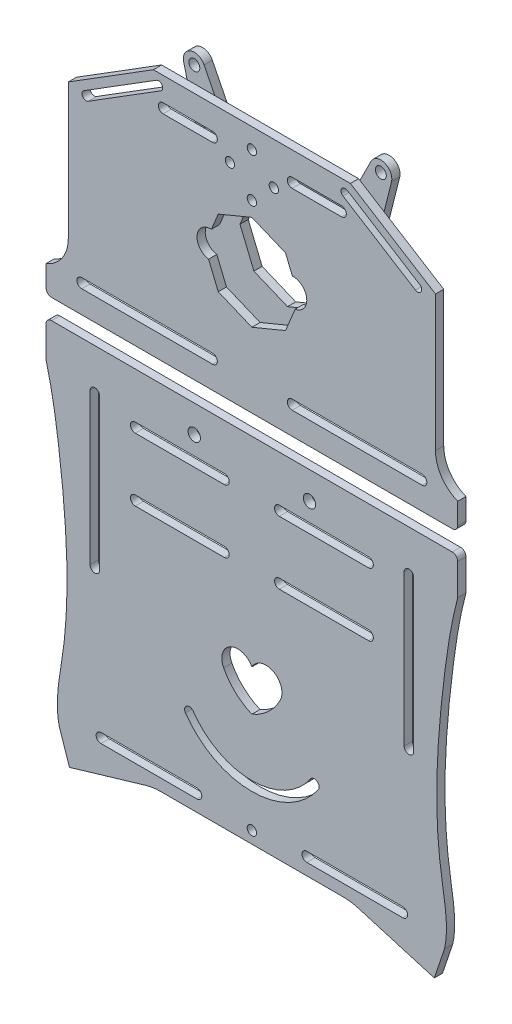
from build123d import *

# Parameters (mm, degrees)
EXTRUDE_1_DEPTH      = 3
SKETCH_7_R           = 1.75
SKETCH_7_R_2         = 2.25
CUT_EXTRUDE_2_DEPTH  = 143.955430949
CUT_EXTRUDE_4_DEPTH  = 3
CUT_EXTRUDE_5_DEPTH  = 3
CUT_EXTRUDE_8_DEPTH  = 3
SKETCH_12_R          = 1.7
CUT_EXTRUDE_9_DEPTH  = 3
SKETCH_13_R          = 1.7
CUT_EXTRUDE_11_DEPTH = 3
CUT_EXTRUDE_12_DEPTH = 143.955430949
FILLET_1_R           = 2
FILLET_2_R           = 2
CUT_EXTRUDE_13_DEPTH = 143.955430949
CUT_EXTRUDE_15_DEPTH = 143.955430949
CUT_EXTRUDE_16_DEPTH = 143.955430949
SKETCH_20_W          = 133.80338819
SKETCH_20_H          = 42.989432067
EXTRUDE_2_DEPTH      = 3
SKETCH_21_W          = 129.207272524
SKETCH_21_H          = 38.788932745
EXTRUDE_3_DEPTH      = 3
SKETCH_22_W          = 20.868569364
SKETCH_22_H          = 31.210515244
SKETCH_22_W_2        = 21.053246969
SKETCH_22_H_2        = 30.102449614
EXTRUDE_4_DEPTH      = 3
SKETCH_24_W          = 36.300662223
SKETCH_24_H          = 5.953308604
SKETCH_24_W_2        = 36.591067521
EXTRUDE_5_DEPTH      = 3
CUT_EXTRUDE_17_DEPTH = 143.955430949
CUT_EXTRUDE_19_DEPTH = 143.955430949
CUT_EXTRUDE_20_DEPTH = 143.955430949
CUT_EXTRUDE_21_DEPTH = 143.955430949
CUT_EXTRUDE_22_DEPTH = 143.955430949
CUT_EXTRUDE_23_DEPTH = 3
SKETCH_30_R          = 1.75
SKETCH_30_R_2        = 2
EXTRUDE_6_DEPTH      = 3
CUT_EXTRUDE_24_DEPTH = 144.816741864


with BuildPart() as part:
    # 草图1 → 凸台-拉伸1 (new body)
    with BuildSketch(Plane.XY):
        with BuildLine():
            Line((60, 106.603296002), (35.889163634, 121.664519159))
            Line((35.889163634, 121.664519159), (-35.889163634, 121.664519159))
            Line((-35.889163634, 121.664519159), (-60, 106.603296002))
            Line((-60, 106.603296002), (-60, 94.801892265))
            Line((-60, 94.801892265), (-45, 94.801892265))
            ThreePointArc((-45, 94.801892265), (-43.762563133, 94.289329132), (-43.25, 93.051892265))
            Line((-43.25, 93.051892265), (-37.75, 93.051892265))
            ThreePointArc((-37.75, 93.051892265), (-37.237436867, 94.289329132), (-36, 94.801892265))
            Line((-36, 94.801892265), (-21, 94.801892265))
            ThreePointArc((-21, 94.801892265), (-19.762563133, 94.289329132), (-19.25, 93.051892265))
            Line((-19.25, 93.051892265), (19.25, 93.051892265))
            ThreePointArc((19.25, 93.051892265), (19.762563133, 94.289329132), (21, 94.801892265))
            Line((21, 94.801892265), (36, 94.801892265))
            ThreePointArc((36, 94.801892265), (37.237436867, 94.289329132), (37.75, 93.051892265))
            Line((37.75, 93.051892265), (43.25, 93.051892265))
            ThreePointArc((43.25, 93.051892265), (43.762563133, 94.289329132), (45, 94.801892265))
            Line((45, 94.801892265), (60, 94.801892265))
            Line((60, 94.801892265), (60, 106.603296002))
        make_face()
        with BuildLine():
            Line((66.901694095, 102.292041372), (60, 106.603296002))
            Line((60, 106.603296002), (60, 94.801892265))
            ThreePointArc((60, 94.801892265), (61.237436867, 94.289329132), (61.75, 93.051892265))
            Line((61.75, 93.051892265), (66.901694095, 93.051892265))
            Line((66.901694095, 93.051892265), (66.901694095, 102.292041372))
        make_face()
        with BuildLine():
            Line((-60, 94.801892265), (-60, 106.603296002))
            Line((-60, 106.603296002), (-66.901694095, 102.292041372))
            Line((-66.901694095, 102.292041372), (-66.901694095, 93.051892265))
            Line((-66.901694095, 93.051892265), (-61.75, 93.051892265))
            ThreePointArc((-61.75, 93.051892265), (-61.237436867, 94.289329132), (-60, 94.801892265))
        make_face()
        with BuildLine():
            Line((66.901694095, 63.051892265), (66.901694095, 93.051892265))
            Line((66.901694095, 93.051892265), (61.75, 93.051892265))
            ThreePointArc((61.75, 93.051892265), (61.237436867, 91.814455398), (60, 91.301892265))
            Line((60, 91.301892265), (60, 64.801892265))
            ThreePointArc((60, 64.801892265), (61.237436867, 64.289329132), (61.75, 63.051892265))
            Line((61.75, 63.051892265), (66.901694095, 63.051892265))
        make_face()
        with BuildLine():
            Line((-61.75, 93.051892265), (-66.901694095, 93.051892265))
            Line((-66.901694095, 93.051892265), (-66.901694095, 63.051892265))
            Line((-66.901694095, 63.051892265), (-61.75, 63.051892265))
            ThreePointArc((-61.75, 63.051892265), (-61.237436867, 64.289329132), (-60, 64.801892265))
            Line((-60, 64.801892265), (-60, 91.301892265))
            ThreePointArc((-60, 91.301892265), (-61.237436867, 91.814455398), (-61.75, 93.051892265))
        make_face()
        with BuildLine():
            Line((66.901694095, 52.870133869), (66.901694095, 63.051892265))
            Line((66.901694095, 63.051892265), (61.75, 63.051892265))
            ThreePointArc((61.75, 63.051892265), (61.237436867, 61.814455398), (60, 61.301892265))
            Line((60, 61.301892265), (60, 31.261343001))
            Line((60, 31.261343001), (75, 31.261343001))
            Line((75, 31.261343001), (75, 40.933889795))
            ThreePointArc((75, 40.933889795), (69.117351927, 45.658052319), (66.901694095, 52.870133869))
        make_face()
        with BuildLine():
            Line((60, 64.801892265), (60, 91.301892265))
            Line((60, 91.301892265), (45, 91.301892265))
            ThreePointArc((45, 91.301892265), (43.762563133, 91.814455398), (43.25, 93.051892265))
            Line((43.25, 93.051892265), (37.75, 93.051892265))
            ThreePointArc((37.75, 93.051892265), (37.237436867, 91.814455398), (36, 91.301892265))
            Line((36, 91.301892265), (21, 91.301892265))
            ThreePointArc((21, 91.301892265), (19.762563133, 91.814455398), (19.25, 93.051892265))
            Line((19.25, 93.051892265), (-19.25, 93.051892265))
            ThreePointArc((-19.25, 93.051892265), (-19.762563133, 91.814455398), (-21, 91.301892265))
            Line((-21, 91.301892265), (-36, 91.301892265))
            ThreePointArc((-36, 91.301892265), (-37.237436867, 91.814455398), (-37.75, 93.051892265))
            Line((-37.75, 93.051892265), (-43.25, 93.051892265))
            ThreePointArc((-43.25, 93.051892265), (-43.762563133, 91.814455398), (-45, 91.301892265))
            Line((-45, 91.301892265), (-60, 91.301892265))
            Line((-60, 91.301892265), (-60, 64.801892265))
            Line((-60, 64.801892265), (-45, 64.801892265))
            ThreePointArc((-45, 64.801892265), (-43.762563133, 64.289329132), (-43.25, 63.051892265))
            Line((-43.25, 63.051892265), (-37.75, 63.051892265))
            ThreePointArc((-37.75, 63.051892265), (-37.237436867, 64.289329132), (-36, 64.801892265))
            Line((-36, 64.801892265), (-21, 64.801892265))
            ThreePointArc((-21, 64.801892265), (-19.762563133, 64.289329132), (-19.25, 63.051892265))
            Line((-19.25, 63.051892265), (19.25, 63.051892265))
            ThreePointArc((19.25, 63.051892265), (19.762563133, 64.289329132), (21, 64.801892265))
            Line((21, 64.801892265), (36, 64.801892265))
            ThreePointArc((36, 64.801892265), (37.237436867, 64.289329132), (37.75, 63.051892265))
            Line((37.75, 63.051892265), (43.25, 63.051892265))
            ThreePointArc((43.25, 63.051892265), (43.762563133, 64.289329132), (45, 64.801892265))
            Line((45, 64.801892265), (60, 64.801892265))
        make_face()
        with BuildLine():
            Line((-61.75, 63.051892265), (-66.901694095, 63.051892265))
            Line((-66.901694095, 63.051892265), (-66.901694095, 52.870133869))
            ThreePointArc((-66.901694095, 52.870133869), (-69.117351927, 45.658052319), (-75, 40.933889795))
            Line((-75, 40.933889795), (-75, 31.261343001))
            Line((-75, 31.261343001), (-60, 31.261343001))
            Line((-60, 31.261343001), (-60, 61.301892265))
            ThreePointArc((-60, 61.301892265), (-61.237436867, 61.814455398), (-61.75, 63.051892265))
        make_face()
        with BuildLine():
            Line((60, 31.261343001), (60, 61.301892265))
            Line((60, 61.301892265), (45, 61.301892265))
            ThreePointArc((45, 61.301892265), (43.762563133, 61.814455398), (43.25, 63.051892265))
            Line((43.25, 63.051892265), (37.75, 63.051892265))
            ThreePointArc((37.75, 63.051892265), (37.237436867, 61.814455398), (36, 61.301892265))
            Line((36, 61.301892265), (21, 61.301892265))
            ThreePointArc((21, 61.301892265), (19.762563133, 61.814455398), (19.25, 63.051892265))
            Line((19.25, 63.051892265), (-19.25, 63.051892265))
            ThreePointArc((-19.25, 63.051892265), (-19.762563133, 61.814455398), (-21, 61.301892265))
            Line((-21, 61.301892265), (-36, 61.301892265))
            ThreePointArc((-36, 61.301892265), (-37.237436867, 61.814455398), (-37.75, 63.051892265))
            Line((-37.75, 63.051892265), (-43.25, 63.051892265))
            ThreePointArc((-43.25, 63.051892265), (-43.762563133, 61.814455398), (-45, 61.301892265))
            Line((-45, 61.301892265), (-60, 61.301892265))
            Line((-60, 61.301892265), (-60, 31.261343001))
            Line((-60, 31.261343001), (60, 31.261343001))
        make_face()
        with BuildLine():
            Line((60, -58.312864289), (60, 23.940028391))
            Line((60, 23.940028391), (-60, 23.940028391))
            Line((-60, 23.940028391), (-60, -58.312864289))
            Line((-60, -58.312864289), (-45, -58.312864289))
            ThreePointArc((-45, -58.312864289), (-43.25, -60.062864289), (-45, -61.812864289))
            Line((-45, -61.812864289), (-60, -61.812864289))
            Line((-60, -61.812864289), (-60, -88.312864289))
            Line((-60, -88.312864289), (-45, -88.312864289))
            ThreePointArc((-45, -88.312864289), (-43.25, -90.062864289), (-45, -91.812864289))
            Line((-45, -91.812864289), (-60, -91.812864289))
            Line((-60, -91.812864289), (-60, -111.849967256))
            Line((-60, -111.849967256), (-38.845469114, -105.590576733))
            ThreePointArc((-38.845469114, -105.590576733), (-36.037784492, -104.975210108), (-33.17088573, -104.768665882))
            Line((-33.17088573, -104.768665882), (33.17088573, -104.768665882))
            ThreePointArc((33.17088573, -104.768665882), (36.037784492, -104.975210108), (38.845469114, -105.590576733))
            Line((38.845469114, -105.590576733), (60, -111.849967256))
            Line((60, -111.849967256), (60, -91.812864289))
            Line((60, -91.812864289), (45, -91.812864289))
            ThreePointArc((45, -91.812864289), (43.762563133, -91.300301156), (43.25, -90.062864289))
            ThreePointArc((43.25, -90.062864289), (43.762563133, -88.825427422), (45, -88.312864289))
            Line((45, -88.312864289), (60, -88.312864289))
            Line((60, -88.312864289), (60, -61.812864289))
            Line((60, -61.812864289), (45, -61.812864289))
            ThreePointArc((45, -61.812864289), (43.762563133, -61.300301156), (43.25, -60.062864289))
            ThreePointArc((43.25, -60.062864289), (43.762563133, -58.825427422), (45, -58.312864289))
            Line((45, -58.312864289), (60, -58.312864289))
        make_face()
        with BuildLine():
            ThreePointArc((-21, -88.312864289), (-19.762563133, -88.825427422), (-19.25, -90.062864289))
            ThreePointArc((-19.25, -90.062864289), (-19.762563133, -91.300301156), (-21, -91.812864289))
            Line((-21, -91.812864289), (-36, -91.812864289))
            ThreePointArc((-36, -91.812864289), (-37.75, -90.062864289), (-36, -88.312864289))
            Line((-36, -88.312864289), (-21, -88.312864289))
        make_face(mode=Mode.SUBTRACT)
        with BuildLine():
            ThreePointArc((-21, -58.312864289), (-19.762563133, -58.825427422), (-19.25, -60.062864289))
            ThreePointArc((-19.25, -60.062864289), (-19.762563133, -61.300301156), (-21, -61.812864289))
            Line((-21, -61.812864289), (-36, -61.812864289))
            ThreePointArc((-36, -61.812864289), (-37.75, -60.062864289), (-36, -58.312864289))
            Line((-36, -58.312864289), (-21, -58.312864289))
        make_face(mode=Mode.SUBTRACT)
        with BuildLine():
            ThreePointArc((36, -88.312864289), (37.237436867, -88.825427422), (37.75, -90.062864289))
            ThreePointArc((37.75, -90.062864289), (37.237436867, -91.300301156), (36, -91.812864289))
            Line((36, -91.812864289), (21, -91.812864289))
            ThreePointArc((21, -91.812864289), (19.762563133, -91.300301156), (19.25, -90.062864289))
            ThreePointArc((19.25, -90.062864289), (19.762563133, -88.825427422), (21, -88.312864289))
            Line((21, -88.312864289), (36, -88.312864289))
        make_face(mode=Mode.SUBTRACT)
        with BuildLine():
            ThreePointArc((36, -58.312864289), (37.237436867, -58.825427422), (37.75, -60.062864289))
            ThreePointArc((37.75, -60.062864289), (37.237436867, -61.300301156), (36, -61.812864289))
            Line((36, -61.812864289), (21, -61.812864289))
            ThreePointArc((21, -61.812864289), (19.762563133, -61.300301156), (19.25, -60.062864289))
            ThreePointArc((19.25, -60.062864289), (19.762563133, -58.825427422), (21, -58.312864289))
            Line((21, -58.312864289), (36, -58.312864289))
        make_face(mode=Mode.SUBTRACT)
        with BuildLine():
            Line((75, 23.940028391), (60, 23.940028391))
            Line((60, 23.940028391), (60, -58.312864289))
            ThreePointArc((60, -58.312864289), (61.237436867, -58.825427422), (61.75, -60.062864289))
            Line((61.75, -60.062864289), (67.402721334, -60.062864289))
            add(Edge.make_bspline(
                [(75, 10.562559835), (72.695878257, 1.907314233), (70.339582535, -13.372796253), (67.818206704, -36.939032951), (67.208860388, -51.77269444), (67.402721334, -60.062864289)],
                knots=[0, 0, 0, 0, 0.235246678, 0.40629419, 0.624108181, 0.624108181, 0.624108181, 0.624108181], degree=3))
            Line((75, 10.562559835), (75, 23.940028391))
        make_face()
        with BuildLine():
            Line((-60, -58.312864289), (-60, 23.940028391))
            Line((-60, 23.940028391), (-75, 23.940028391))
            Line((-75, 23.940028391), (-75, 10.562559835))
            add(Edge.make_bspline(
                [(-75, 10.562559835), (-72.695878257, 1.907314233), (-70.339582535, -13.372796253), (-67.818206704, -36.939032951), (-67.208860388, -51.77269444), (-67.402721334, -60.062864289)],
                knots=[0, 0, 0, 0, 0.235246678, 0.40629419, 0.624108181, 0.624108181, 0.624108181, 0.624108181], degree=3))
            add(Edge.make_bspline(
                [(-67.402721334, -60.062864289), (-67.560325872, -66.802583754), (-68.323504015, -76.843670093), (-70.154131955, -86.778530076), (-70.533712858, -90.062864289)],
                knots=[0.624108181, 0.624108181, 0.624108181, 0.624108181, 0.801186001, 0.888408652, 0.888408652, 0.888408652, 0.888408652], degree=3))
            add(Edge.make_bspline(
                [(-70.533712858, -90.062864289), (-71.019342956, -94.264792095), (-71.137422935, -98.476048206), (-70.1742624, -102.732794059)],
                knots=[0.888408652, 0.888408652, 0.888408652, 0.888408652, 1, 1, 1, 1], degree=3))
            Line((-70.1742624, -102.732794059), (-66.460817635, -113.761651372))
            Line((-66.460817635, -113.761651372), (-60, -111.849967256))
            Line((-60, -111.849967256), (-60, -91.812864289))
            ThreePointArc((-60, -91.812864289), (-61.75, -90.062864289), (-60, -88.312864289))
            Line((-60, -88.312864289), (-60, -61.812864289))
            ThreePointArc((-60, -61.812864289), (-61.75, -60.062864289), (-60, -58.312864289))
        make_face()
        with BuildLine():
            Line((67.402721334, -60.062864289), (61.75, -60.062864289))
            ThreePointArc((61.75, -60.062864289), (61.237436867, -61.300301156), (60, -61.812864289))
            Line((60, -61.812864289), (60, -88.312864289))
            ThreePointArc((60, -88.312864289), (61.237436867, -88.825427422), (61.75, -90.062864289))
            Line((61.75, -90.062864289), (70.533712858, -90.062864289))
            add(Edge.make_bspline(
                [(67.402721334, -60.062864289), (67.560325872, -66.802583754), (68.323504015, -76.843670093), (70.154131955, -86.778530076), (70.533712858, -90.062864289)],
                knots=[0.624108181, 0.624108181, 0.624108181, 0.624108181, 0.801186001, 0.888408652, 0.888408652, 0.888408652, 0.888408652], degree=3))
        make_face()
        with BuildLine():
            add(Edge.make_bspline(
                [(70.533712858, -90.062864289), (71.019342956, -94.264792095), (71.137422935, -98.476048206), (70.1742624, -102.732794059)],
                knots=[0.888408652, 0.888408652, 0.888408652, 0.888408652, 1, 1, 1, 1], degree=3))
            Line((70.533712858, -90.062864289), (61.75, -90.062864289))
            ThreePointArc((61.75, -90.062864289), (61.237436867, -91.300301156), (60, -91.812864289))
            Line((60, -91.812864289), (60, -111.849967256))
            Line((60, -111.849967256), (66.460817635, -113.761651372))
            Line((66.460817635, -113.761651372), (70.1742624, -102.732794059))
        make_face()
    extrude(amount=EXTRUDE_1_DEPTH)

    # 草图7 → 切除-拉伸2 (cut, through all)
    with BuildSketch(Plane(origin=(0, 0, 0), x_dir=(-1, 0, 0), z_dir=(0, 0, -1))):
        with Locations((-21, 41.261343001)):
            Circle(SKETCH_7_R)
        with Locations((21, 41.261343001)):
            Circle(SKETCH_7_R)
        with Locations((-21, 13.940028391)):
            Circle(SKETCH_7_R_2)
        with Locations((21, 13.940028391)):
            Circle(SKETCH_7_R_2)
    extrude(amount=-CUT_EXTRUDE_2_DEPTH, mode=Mode.SUBTRACT)

    # 草图9 → 切除-拉伸4 (cut)
    with BuildSketch(Plane.XY.offset(3)):
        with BuildLine():
            Line((55, -100.49704609), (20, -100.49704609))
            ThreePointArc((20, -100.49704609), (18.25, -98.74704609), (20, -96.99704609))
            Line((20, -96.99704609), (55, -96.99704609))
            ThreePointArc((55, -96.99704609), (56.75, -98.74704609), (55, -100.49704609))
        make_face()
        with BuildLine():
            Line((-55, -96.99704609), (-20, -96.99704609))
            ThreePointArc((-20, -96.99704609), (-18.25, -98.74704609), (-20, -100.49704609))
            Line((-20, -100.49704609), (-55, -100.49704609))
            ThreePointArc((-55, -100.49704609), (-56.75, -98.74704609), (-55, -96.99704609))
        make_face()
    extrude(amount=-CUT_EXTRUDE_4_DEPTH, mode=Mode.SUBTRACT)

    # 草图10 → 切除-拉伸5 (cut)
    with BuildSketch(Plane.XY.offset(3)):
        with BuildLine():
            Line((12.5, -80.062864289), (-12.5, -80.062864289))
            ThreePointArc((-12.5, -80.062864289), (-17.5, -75.062864289), (-12.5, -70.062864289))
            Line((-12.5, -70.062864289), (12.5, -70.062864289))
            ThreePointArc((12.5, -70.062864289), (17.5, -75.062864289), (12.5, -80.062864289))
        make_face()
    extrude(amount=-CUT_EXTRUDE_5_DEPTH, mode=Mode.SUBTRACT)

    # 草图11 → 切除-拉伸8 (cut)
    with BuildSketch(Plane.XY.offset(3)):
        with BuildLine():
            Line((15, 73.051892265), (-15, 73.051892265))
            ThreePointArc((-15, 73.051892265), (-20, 78.051892265), (-15, 83.051892265))
            Line((-15, 83.051892265), (15, 83.051892265))
            ThreePointArc((15, 83.051892265), (20, 78.051892265), (15, 73.051892265))
        make_face()
    extrude(amount=-CUT_EXTRUDE_8_DEPTH, mode=Mode.SUBTRACT)

    # 草图12 → 切除-拉伸9 (cut)
    with BuildSketch(Plane.XY.offset(3)):
        with Locations((0, 114.371786435)):
            Circle(SKETCH_12_R)
        with Locations((0, 98.371786435)):
            Circle(SKETCH_12_R)
        with Locations((8, 106.371786435)):
            Circle(SKETCH_12_R)
        with Locations((-8, 106.371786435)):
            Circle(SKETCH_12_R)
    extrude(amount=-CUT_EXTRUDE_9_DEPTH, mode=Mode.SUBTRACT)

    # 草图13 → 切除-拉伸11 (cut)
    with BuildSketch(Plane.XY.offset(3)):
        with Locations((0, -84.415765086)):
            Circle(SKETCH_13_R)
        with Locations((8, -92.415765086)):
            Circle(SKETCH_13_R)
        with Locations((0, -100.415765086)):
            Circle(SKETCH_13_R)
        with Locations((-8, -92.415765086)):
            Circle(SKETCH_13_R)
    extrude(amount=-CUT_EXTRUDE_11_DEPTH, mode=Mode.SUBTRACT)

    # 草图14 → 切除-拉伸12 (cut, through all)
    with BuildSketch(Plane.XY.offset(3)):
        with BuildLine():
            Line((-55.475501567, 8.919687236), (-55.475501567, -46.080312764))
            ThreePointArc((-55.475501567, -46.080312764), (-57.225501567, -47.830312764), (-58.975501567, -46.080312764))
            Line((-58.975501567, -46.080312764), (-58.975501567, 8.919687236))
            ThreePointArc((-58.975501567, 8.919687236), (-57.225501567, 10.669687236), (-55.475501567, 8.919687236))
        make_face()
        with BuildLine():
            Line((58.975501567, 8.919687236), (58.975501567, -46.080312764))
            ThreePointArc((58.975501567, -46.080312764), (57.225501567, -47.830312764), (55.475501567, -46.080312764))
            Line((55.475501567, -46.080312764), (55.475501567, 8.919687236))
            ThreePointArc((55.475501567, 8.919687236), (57.225501567, 10.669687236), (58.975501567, 8.919687236))
        make_face()
    extrude(amount=-CUT_EXTRUDE_12_DEPTH, mode=Mode.SUBTRACT)

    # 圆角1
    fillet_1_edges = [part.edges().sort_by_distance(p)[0] for p in [
        (75, 31.261343001, 1.5),
        (-75, 31.261343001, 1.5),
    ]]
    fillet(fillet_1_edges, radius=FILLET_1_R)

    # 圆角2
    fillet_2_edges = [part.edges().sort_by_distance(p)[0] for p in [
        (-75, 23.940028391, 1.5),
        (75, 23.940028391, 1.5),
    ]]
    fillet(fillet_2_edges, radius=FILLET_2_R)

    # 草图15 → 切除-拉伸13 (cut, through all)
    with BuildSketch(Plane(origin=(0, 0, 0), x_dir=(-1, 0, 0), z_dir=(0, 0, -1))):
        with BuildLine():
            Line((-61.184216401, 102.403501276), (-34.774762862, 118.900592756))
            ThreePointArc((-34.774762862, 118.900592756), (-32.70788159, 118.423097411), (-33.185376934, 116.356216138))
            Line((-33.185376934, 116.356216138), (-59.594830473, 99.859124658))
            ThreePointArc((-59.594830473, 99.859124658), (-61.661711746, 100.336620003), (-61.184216401, 102.403501276))
        make_face()
        with BuildLine():
            Line((59.594830473, 99.859124658), (33.185376934, 116.356216138))
            ThreePointArc((33.185376934, 116.356216138), (32.70788159, 118.423097411), (34.774762862, 118.900592756))
            Line((34.774762862, 118.900592756), (61.184216401, 102.403501276))
            ThreePointArc((61.184216401, 102.403501276), (61.661711746, 100.336620003), (59.594830473, 99.859124658))
        make_face()
    extrude(amount=-CUT_EXTRUDE_13_DEPTH, mode=Mode.SUBTRACT)

    # 草图17 → 切除-拉伸15 (cut, through all)
    with BuildSketch(Plane(origin=(0, 0, 0), x_dir=(-1, 0, 0), z_dir=(0, 0, -1))):
        Polygon((-28.645414283, -8.118433382), (-34.644957411, -20.11751964), (-34.644957411, -29.946558382), (-37.580904049, -29.946558382), (-37.580904049, -20.11751964), (-43.580447177, -8.118433382), (-40.64450054, -8.118433382), (-36.176755657, -17.43687271), (-36.049105803, -17.43687271), (-31.58136092, -8.118433382), align=None)
    extrude(amount=-CUT_EXTRUDE_15_DEPTH, mode=Mode.SUBTRACT)

    # 草图18 → 切除-拉伸16 (cut, through all)
    with BuildSketch(Plane(origin=(0, 0, 0), x_dir=(-1, 0, 0), z_dir=(0, 0, -1))):
        Polygon((46.06697123, -29.087529791), (43.131024593, -29.087529791), (43.131024593, -18.875541487), (35.854982926, -18.875541487), (35.854982926, -29.087529791), (32.919036289, -29.087529791), (32.919036289, -7.259404791), (35.854982926, -7.259404791), (35.854982926, -16.450194265), (43.131024593, -16.450194265), (43.131024593, -7.259404791), (46.06697123, -7.259404791), align=None)
    extrude(amount=-CUT_EXTRUDE_16_DEPTH, mode=Mode.SUBTRACT)

    # 草图20 → 凸台-拉伸2 (add)
    with BuildSketch(Plane(origin=(0, 0, 0), x_dir=(-1, 0, 0), z_dir=(0, 0, -1))):
        with Locations((0, 74.364849902)):
            Rectangle(SKETCH_20_W, SKETCH_20_H)
    extrude(amount=-EXTRUDE_2_DEPTH)

    # 草图21 → 凸台-拉伸3 (add)
    with BuildSketch(Plane(origin=(0, 0, 0), x_dir=(-1, 0, 0), z_dir=(0, 0, -1))):
        with Locations((-0.162688936, -75.817262983)):
            Rectangle(SKETCH_21_W, SKETCH_21_H)
    extrude(amount=-EXTRUDE_3_DEPTH)

    # 草图22 → 凸台-拉伸4 (add)
    with BuildSketch(Plane(origin=(0, 0, 0), x_dir=(-1, 0, 0), z_dir=(0, 0, -1))):
        with Locations((-36.28455521, -18.718035035)):
            Rectangle(SKETCH_22_W, SKETCH_22_H)
        with Locations((39.340924035, -18.16400222)):
            Rectangle(SKETCH_22_W_2, SKETCH_22_H_2)
    extrude(amount=-EXTRUDE_4_DEPTH)

    # 草图24 → 凸台-拉伸5 (add)
    with BuildSketch(Plane(origin=(0, 0, 0), x_dir=(-1, 0, 0), z_dir=(0, 0, -1))):
        with Locations((-46.84572901, 41.350914957)):
            Rectangle(SKETCH_24_W, SKETCH_24_H)
        with Locations((47.53599277, 41.350914957)):
            Rectangle(SKETCH_24_W_2, SKETCH_24_H)
    extrude(amount=-EXTRUDE_5_DEPTH)

    # 草图25 → 切除-拉伸17 (cut, through all)
    with BuildSketch(Plane(origin=(0, 0, 0), x_dir=(-1, 0, 0), z_dir=(0, 0, -1))):
        with BuildLine():
            Line((-14.658238954, 113.011343001), (-32.658238954, 113.011343001))
            ThreePointArc((-32.658238954, 113.011343001), (-34.408238954, 111.261343001), (-32.658238954, 109.511343001))
            Line((-32.658238954, 109.511343001), (-14.658238954, 109.511343001))
            ThreePointArc((-14.658238954, 109.511343001), (-12.908238954, 111.261343001), (-14.658238954, 113.011343001))
        make_face()
        with BuildLine():
            Line((-20.999999982, 43.011343001), (-32.658238954, 43.011343001))
            ThreePointArc((-32.658238954, 43.011343001), (-34.408238954, 41.261343001), (-32.658238954, 39.511343001))
            Line((-32.658238954, 39.511343001), (-21, 39.511343001))
            ThreePointArc((-21, 39.511343001), (-22.75, 41.26134301), (-20.999999982, 43.011343001))
        make_face()
        with BuildLine():
            ThreePointArc((14.341761046, 113.011343001), (12.591761046, 111.261343001), (14.341761046, 109.511343001))
            Line((14.341761046, 109.511343001), (32.341761046, 109.511343001))
            ThreePointArc((32.341761046, 109.511343001), (34.091761046, 111.261343001), (32.341761046, 113.011343001))
            Line((32.341761046, 113.011343001), (14.341761046, 113.011343001))
        make_face()
        with BuildLine():
            Line((-14.658238954, 43.011343001), (-20.999999982, 43.011343001))
            ThreePointArc((-20.999999982, 43.011343001), (-19.25, 41.261342991), (-21, 39.511343001))
            Line((-21, 39.511343001), (-14.658238954, 39.511343001))
            ThreePointArc((-14.658238954, 39.511343001), (-12.908238954, 41.261343001), (-14.658238954, 43.011343001))
        make_face()
        with BuildLine():
            ThreePointArc((32.341761046, 39.511343001), (34.091761046, 41.261343001), (32.341761046, 43.011343001))
            Line((32.341761046, 43.011343001), (21, 43.011343001))
            ThreePointArc((21, 43.011343001), (22.75, 41.261343001), (21, 39.511343001))
            Line((21, 39.511343001), (32.341761046, 39.511343001))
        make_face()
        with BuildLine():
            ThreePointArc((14.341761046, 43.011343001), (12.591761046, 41.261343001), (14.341761046, 39.511343001))
            Line((14.341761046, 39.511343001), (21, 39.511343001))
            ThreePointArc((21, 39.511343001), (19.25, 41.261343001), (21, 43.011343001))
            Line((21, 43.011343001), (14.341761046, 43.011343001))
        make_face()
    extrude(amount=-CUT_EXTRUDE_17_DEPTH, mode=Mode.SUBTRACT)

    # 草图16 → 切除-拉伸19 (cut, through all)
    with BuildSketch(Plane(origin=(0, 0, 0), x_dir=(-1, 0, 0), z_dir=(0, 0, -1))):
        with BuildLine():
            Line((-62, 43.011343001), (-32, 43.011343001))
            ThreePointArc((-32, 43.011343001), (-30.25, 41.261343001), (-32, 39.511343001))
            Line((-32, 39.511343001), (-62, 39.511343001))
            ThreePointArc((-62, 39.511343001), (-63.75, 41.261343001), (-62, 43.011343001))
        make_face()
        with BuildLine():
            Line((62, 39.511343001), (32, 39.511343001))
            ThreePointArc((32, 39.511343001), (30.25, 41.261343001), (32, 43.011343001))
            Line((32, 43.011343001), (62, 43.011343001))
            ThreePointArc((62, 43.011343001), (63.75, 41.261343001), (62, 39.511343001))
        make_face()
    extrude(amount=-CUT_EXTRUDE_19_DEPTH, mode=Mode.SUBTRACT)

    # 草图26 → 切除-拉伸20 (cut, through all)
    with BuildSketch(Plane(origin=(0, 0, 0), x_dir=(-1, 0, 0), z_dir=(0, 0, -1))):
        with BuildLine():
            Line((15, 71.876956146), (-15, 71.876956146))
            ThreePointArc((-15, 71.876956146), (-20, 76.876956146), (-15, 81.876956146))
            Line((-15, 81.876956146), (15, 81.876956146))
            ThreePointArc((15, 81.876956146), (20, 76.876956146), (15, 71.876956146))
        make_face()
    extrude(amount=-CUT_EXTRUDE_20_DEPTH, mode=Mode.SUBTRACT)

    # 草图27 → 切除-拉伸21 (cut, through all)
    with BuildSketch(Plane(origin=(0, 0, 0), x_dir=(-1, 0, 0), z_dir=(0, 0, -1))):
        with BuildLine():
            Line((-10, -15.809971609), (-42.5, -15.809971609))
            ThreePointArc((-42.5, -15.809971609), (-44.25, -17.559971609), (-42.5, -19.309971609))
            Line((-42.5, -19.309971609), (-10, -19.309971609))
            ThreePointArc((-10, -19.309971609), (-8.25, -17.559971609), (-10, -15.809971609))
        make_face()
        with BuildLine():
            ThreePointArc((-42.5, 7.190028391), (-44.25, 5.440028391), (-42.5, 3.690028391))
            Line((-42.5, 3.690028391), (-10, 3.690028391))
            ThreePointArc((-10, 3.690028391), (-8.25, 5.440028391), (-10, 7.190028391))
            Line((-10, 7.190028391), (-42.5, 7.190028391))
        make_face()
        with BuildLine():
            Line((42.5, -15.809971609), (10, -15.809971609))
            ThreePointArc((10, -15.809971609), (8.25, -17.559971609), (10, -19.309971609))
            Line((10, -19.309971609), (42.5, -19.309971609))
            ThreePointArc((42.5, -19.309971609), (44.25, -17.559971609), (42.5, -15.809971609))
        make_face()
        with BuildLine():
            Line((42.5, 7.190028391), (10, 7.190028391))
            ThreePointArc((10, 7.190028391), (8.25, 5.440028391), (10, 3.690028391))
            Line((10, 3.690028391), (42.5, 3.690028391))
            ThreePointArc((42.5, 3.690028391), (44.25, 5.440028391), (42.5, 7.190028391))
        make_face()
    extrude(amount=-CUT_EXTRUDE_21_DEPTH, mode=Mode.SUBTRACT)

    # 草图28 → 切除-拉伸22 (cut, through all)
    with BuildSketch(Plane(origin=(0, 0, 0), x_dir=(-1, 0, 0), z_dir=(0, 0, -1))):
        with BuildLine():
            ThreePointArc((0, -48.812330529), (-7.86916468, -46.39674179), (-10.284753419, -54.26590647))
            ThreePointArc((-10.284753419, -54.26590647), (-5.977554294, -59.915955393), (0, -63.755729058))
            ThreePointArc((0, -63.755729058), (5.977554294, -59.915955393), (10.284753419, -54.26590647))
            ThreePointArc((10.284753419, -54.26590647), (7.86916468, -46.39674179), (0, -48.812330529))
        make_face()
    extrude(amount=-CUT_EXTRUDE_22_DEPTH, mode=Mode.SUBTRACT)

    # 草图29 → 切除-拉伸23 (cut)
    with BuildSketch(Plane(origin=(0, 0, 0), x_dir=(-1, 0, 0), z_dir=(0, 0, -1))):
        with BuildLine():
            ThreePointArc((-21.368709037, -73.490793052), (0, -84.713248851), (21.368709037, -73.490793052))
            ThreePointArc((21.368709037, -73.490793052), (23.760053677, -73.051240341), (24.199606389, -75.442584981))
            ThreePointArc((24.199606389, -75.442584981), (0, -88.151776376), (-24.199606389, -75.442584981))
            ThreePointArc((-24.199606389, -75.442584981), (-23.760053677, -73.051240341), (-21.368709037, -73.490793052))
        make_face()
    extrude(amount=-CUT_EXTRUDE_23_DEPTH, mode=Mode.SUBTRACT)


with BuildPart() as body_2:
    # 草图30 → 凸台-拉伸6 (new body)
    with BuildSketch(Plane(origin=(0, 0, -10), x_dir=(-1, 0, 0), z_dir=(0, 0, -1))):
        with BuildLine():
            Line((-37.859742659, 116.654680014), (-32.650409049, 95.89879773))
            ThreePointArc((-32.650409049, 95.89879773), (-32.537744729, 95.294849024), (-32.5, 94.681642189))
            Line((-32.5, 94.681642189), (-32.5, 56.67564656))
            ThreePointArc((-32.5, 56.67564656), (-32.590476351, 55.728768774), (-32.858631016, 54.816159007))
            Line((-32.858631016, 54.816159007), (-37.693165085, 42.748933043))
            ThreePointArc((-37.693165085, 42.748933043), (-36.249359534, 37.967359918), (-31.267161846, 38.321933213))
            Line((-31.267161846, 38.321933213), (-23.882893059, 45.137193314))
            ThreePointArc((-23.882893059, 45.137193314), (-22.312292095, 46.119717051), (-20.491757994, 46.46293108))
            Line((-20.491757994, 46.46293108), (20.491757994, 46.46293108))
            ThreePointArc((20.491757994, 46.46293108), (22.312292095, 46.119717051), (23.882893059, 45.137193314))
            Line((23.882893059, 45.137193314), (31.267161846, 38.321933213))
            ThreePointArc((31.267161846, 38.321933213), (36.249359534, 37.967359918), (37.693165085, 42.748933043))
            Line((37.693165085, 42.748933043), (32.858631016, 54.816159007))
            ThreePointArc((32.858631016, 54.816159007), (32.590476351, 55.728768774), (32.5, 56.67564656))
            Line((32.5, 56.67564656), (32.5, 94.681642189))
            ThreePointArc((32.5, 94.681642189), (32.537744729, 95.294849024), (32.650409049, 95.89879773))
            Line((32.650409049, 95.89879773), (37.859742659, 116.654680014))
            ThreePointArc((37.859742659, 116.654680014), (35.370552011, 121.378945674), (30.403282719, 119.419100812))
            Line((30.403282719, 119.419100812), (25.299449269, 109.224560624))
            ThreePointArc((25.299449269, 109.224560624), (23.456025733, 107.20900041), (20.828465294, 106.46293108))
            Line((20.828465294, 106.46293108), (-20.828465294, 106.46293108))
            ThreePointArc((-20.828465294, 106.46293108), (-23.456025733, 107.20900041), (-25.299449269, 109.224560624))
            Line((-25.299449269, 109.224560624), (-30.403282719, 119.419100812))
            ThreePointArc((-30.403282719, 119.419100812), (-35.370552011, 121.378945674), (-37.859742659, 116.654680014))
        make_face()
        with Locations((-29, 100.96293108)):
            Circle(SKETCH_30_R, mode=Mode.SUBTRACT)
        with Locations((29, 100.96293108)):
            Circle(SKETCH_30_R, mode=Mode.SUBTRACT)
        with Locations((-29, 51.96293108)):
            Circle(SKETCH_30_R, mode=Mode.SUBTRACT)
        with Locations((29, 51.96293108)):
            Circle(SKETCH_30_R, mode=Mode.SUBTRACT)
        with Locations((-33.980069898, 117.628404447)):
            Circle(SKETCH_30_R_2, mode=Mode.SUBTRACT)
        with Locations(Location((33.980069898, 117.628404447, 0), (0, 0, 180))):
            Circle(SKETCH_30_R_2, mode=Mode.SUBTRACT)
        with Locations((-33.980069898, 41.261343001)):
            Circle(SKETCH_30_R_2, mode=Mode.SUBTRACT)
        with Locations((33.980069898, 41.261343001)):
            Circle(SKETCH_30_R_2, mode=Mode.SUBTRACT)
    extrude(amount=EXTRUDE_6_DEPTH)


with BuildPart() as cut_extrude_24_tool:
    # 草图31 → 切除-拉伸24 (new, through all)
    with BuildSketch(Plane(origin=(0, 0, -13), x_dir=(-1, 0, 0), z_dir=(0, 0, -1))):
        Polygon((0, 93.009245207), (-12.254585371, 87.933229745), (-17.330600833, 75.678644374), (-12.254585371, 63.424059003), (0, 58.348043542), (12.254585371, 63.424059003), (17.330600833, 75.678644374), (12.254585371, 87.933229745), align=None)
    extrude(amount=-CUT_EXTRUDE_24_DEPTH)


with BuildPart() as part_1:
    add(part.part)

    # 切除-拉伸24: cut by cut_extrude_24_tool
    add(cut_extrude_24_tool.part, mode=Mode.SUBTRACT)


with BuildPart() as body_2_1:
    add(body_2.part)

    # 切除-拉伸24: cut by cut_extrude_24_tool
    add(cut_extrude_24_tool.part, mode=Mode.SUBTRACT)


solid = Compound([part_1.part, body_2_1.part])
